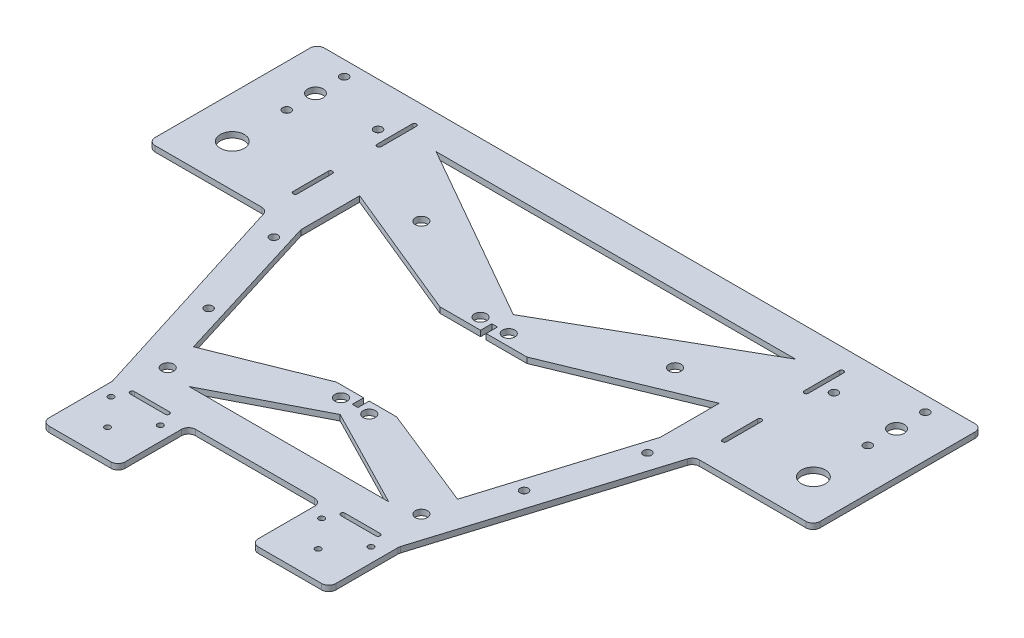
from build123d import *

# Parameters (mm, degrees)
SKETCH26_R          = 1
SKETCH26_R_2        = 2.15
SKETCH26_R_3        = 1.45
SKETCH26_R_4        = 4.25
SKETCH26_R_5        = 2.75
BOSS_EXTRUDE4_DEPTH = 2


with BuildPart() as part:
    # Sketch26 → Boss-Extrude4 (new body)
    with BuildSketch(Plane(origin=(0, 0, 0), x_dir=(1, 0, 0), z_dir=(0, 1, 0))):
        with BuildLine():
            Line((-20.877618357, -51.176455051), (21.352676296, -51.176455051))
            ThreePointArc((21.352676296, -51.176455051), (23.120443249, -51.908688098), (23.852676296, -53.676455051))
            Line((23.852676296, -53.676455051), (23.852676296, -73.676455051))
            ThreePointArc((23.852676296, -73.676455051), (24.584909343, -75.444222004), (26.352676296, -76.176455051))
            Line((26.352676296, -76.176455051), (48.872676296, -76.176455051))
            ThreePointArc((48.872676296, -76.176455051), (50.640443249, -75.444222004), (51.372676296, -73.676455051))
            Line((51.372676296, -73.676455051), (51.372676296, -51.552742091))
            ThreePointArc((51.372676296, -51.552742091), (51.400522432, -51.180646307), (51.483440514, -50.816839667))
            Line((51.483440514, -50.816839667), (75.469917209, 27.059447373))
            ThreePointArc((75.469917209, 27.059447373), (76.374187682, 28.334733163), (77.859152991, 28.823544949))
            Line((77.859152991, 28.823544949), (115.689249226, 28.823544949))
            ThreePointArc((115.689249226, 28.823544949), (117.457016179, 29.555777996), (118.189249226, 31.323544949))
            Line((118.189249226, 31.323544949), (118.189249226, 86.323544949))
            ThreePointArc((118.189249226, 86.323544949), (117.457016179, 88.091311902), (115.689249226, 88.823544949))
            Line((115.689249226, 88.823544949), (76.013272408, 88.823544949))
            Line((76.013272408, 88.823544949), (-75.538214468, 88.823544949))
            Line((-75.538214468, 88.823544949), (-76.032763958, 88.823544949))
            Line((-76.032763958, 88.823544949), (-115.214191287, 88.823544949))
            ThreePointArc((-115.214191287, 88.823544949), (-116.98195824, 88.091311902), (-117.714191287, 86.323544949))
            Line((-117.714191287, 86.323544949), (-117.714191287, 31.323544949))
            ThreePointArc((-117.714191287, 31.323544949), (-116.98195824, 29.555777996), (-115.214191287, 28.823544949))
            Line((-115.214191287, 28.823544949), (-77.373372177, 28.823544949))
            ThreePointArc((-77.373372177, 28.823544949), (-75.894006821, 28.338855879), (-74.98826724, 27.072727465))
            Line((-74.98826724, 27.072727465), (-50.52440331, -50.81067398))
            ThreePointArc((-50.52440331, -50.81067398), (-50.438398947, -51.180885745), (-50.409508246, -51.559856495))
            Line((-50.409508246, -51.559856495), (-50.409508246, -73.676455051))
            ThreePointArc((-50.409508246, -73.676455051), (-49.677275199, -75.444222004), (-47.909508246, -76.176455051))
            Line((-47.909508246, -76.176455051), (-25.877618357, -76.176455051))
            ThreePointArc((-25.877618357, -76.176455051), (-24.109851404, -75.444222004), (-23.377618357, -73.676455051))
            Line((-23.377618357, -73.676455051), (-23.377618357, -53.676455051))
            ThreePointArc((-23.377618357, -53.676455051), (-22.64538531, -51.908688098), (-20.877618357, -51.176455051))
        make_face()
        with Locations((-37.137618357, -66.176455051)):
            Circle(SKETCH26_R, mode=Mode.SUBTRACT)
        with Locations((-45.897618357, -56.176455051)):
            Circle(SKETCH26_R, mode=Mode.SUBTRACT)
        with Locations((-28.377618357, -56.176455051)):
            Circle(SKETCH26_R, mode=Mode.SUBTRACT)
        with BuildLine():
            Line((-43.378108588, -50.422722318), (-30.878108588, -50.422722318))
            ThreePointArc((-30.878108588, -50.422722318), (-30.128108588, -51.172722318), (-30.878108588, -51.922722318))
            Line((-30.878108588, -51.922722318), (-43.378108588, -51.922722318))
            ThreePointArc((-43.378108588, -51.922722318), (-44.128108588, -51.172722318), (-43.378108588, -50.422722318))
        make_face(mode=Mode.SUBTRACT)
        with Locations((-44.76247103, -37.176455051)):
            Circle(SKETCH26_R_2, mode=Mode.SUBTRACT)
        with Locations((-4.76247103, -15.676455051)):
            Circle(SKETCH26_R_2, mode=Mode.SUBTRACT)
        with Locations((-55.732763009, -11.697986619)):
            Circle(SKETCH26_R_3, mode=Mode.SUBTRACT)
        with Locations((28.852676296, -56.176455051)):
            Circle(SKETCH26_R, mode=Mode.SUBTRACT)
        with Locations((37.612676296, -66.176455051)):
            Circle(SKETCH26_R, mode=Mode.SUBTRACT)
        with Locations((46.372676296, -56.176455051)):
            Circle(SKETCH26_R, mode=Mode.SUBTRACT)
        with BuildLine():
            ThreePointArc((31.353166528, -51.922722318), (30.603166528, -51.172722318), (31.353166528, -50.422722318))
            Line((31.353166528, -50.422722318), (43.853166528, -50.422722318))
            ThreePointArc((43.853166528, -50.422722318), (44.603166528, -51.172722318), (43.853166528, -51.922722318))
            Line((43.853166528, -51.922722318), (31.353166528, -51.922722318))
        make_face(mode=Mode.SUBTRACT)
        with Locations((45.23752897, -37.176455051)):
            Circle(SKETCH26_R_2, mode=Mode.SUBTRACT)
        Polygon((35.658255702, -39.176455051), (-35.183197763, -39.176455051), (0.23752897, -20.965122509), align=None, mode=Mode.SUBTRACT)
        with Locations((5.23752897, -15.676455051)):
            Circle(SKETCH26_R_2, mode=Mode.SUBTRACT)
        with Locations((56.207820949, -11.697986619)):
            Circle(SKETCH26_R_3, mode=Mode.SUBTRACT)
        with Locations((-66.035396945, 21.75131433)):
            Circle(SKETCH26_R_3, mode=Mode.SUBTRACT)
        with Locations((-102.838214468, 43.823544949)):
            Circle(SKETCH26_R_4, mode=Mode.SUBTRACT)
        with BuildLine():
            ThreePointArc((-75.160005035, 39.191107079), (-75.910005035, 38.441107079), (-76.660005035, 39.191107079))
            Line((-76.660005035, 39.191107079), (-76.660005035, 51.691107079))
            ThreePointArc((-76.660005035, 51.691107079), (-75.910005035, 52.441107079), (-75.160005035, 51.691107079))
            Line((-75.160005035, 51.691107079), (-75.160005035, 39.191107079))
        make_face(mode=Mode.SUBTRACT)
        Polygon((-10.456903842, -11.676455051), (-46.597804641, -26.176455051), (-63.538214468, 28.823544949), (-63.538214468, 49.70968094), (-15.178445609, 29.823544949), (-0.76247103, 29.823544949), (-0.76247103, 33.823544949), (1.23752897, 33.823544949), (1.23752897, 29.823544949), (15.653503549, 29.823544949), (64.013272408, 49.70968094), (64.013272408, 28.823544949), (47.072862581, -26.176455051), (10.931961782, -11.676455051), (1.23752897, -11.676455051), (1.23752897, -15.676455051), (-0.76247103, -15.676455051), (-0.76247103, -11.676455051), align=None, mode=Mode.SUBTRACT)
        with Locations((-4.76247103, 33.823544949)):
            Circle(SKETCH26_R_2, mode=Mode.SUBTRACT)
        with Locations((-102.838214468, 63.123544949)):
            Circle(SKETCH26_R_3, mode=Mode.SUBTRACT)
        with Locations((-102.838214468, 73.323544949)):
            Circle(SKETCH26_R_5, mode=Mode.SUBTRACT)
        with Locations((-102.838214468, 83.523544949)):
            Circle(SKETCH26_R_3, mode=Mode.SUBTRACT)
        with Locations((-80.638214468, 73.323544949)):
            Circle(SKETCH26_R_3, mode=Mode.SUBTRACT)
        with BuildLine():
            ThreePointArc((-76.288214468, 81.095149015), (-75.538214468, 81.845149015), (-74.788214468, 81.095149015))
            Line((-74.788214468, 81.095149015), (-74.788214468, 68.595149015))
            ThreePointArc((-74.788214468, 68.595149015), (-75.538214468, 67.845149015), (-76.288214468, 68.595149015))
            Line((-76.288214468, 68.595149015), (-76.288214468, 81.095149015))
        make_face(mode=Mode.SUBTRACT)
        with Locations((-44.76247103, 52.823544949)):
            Circle(SKETCH26_R_2, mode=Mode.SUBTRACT)
        Polygon((0.23752897, 40.436613896), (-63.538214468, 76.823544949), (64.013272408, 76.823544949), align=None, mode=Mode.SUBTRACT)
        with Locations((5.23752897, 33.823544949)):
            Circle(SKETCH26_R_2, mode=Mode.SUBTRACT)
        with Locations((66.510454885, 21.75131433)):
            Circle(SKETCH26_R_3, mode=Mode.SUBTRACT)
        with BuildLine():
            Line((77.135062974, 51.691107079), (77.135062974, 39.191107079))
            ThreePointArc((77.135062974, 39.191107079), (76.385062974, 38.441107079), (75.635062974, 39.191107079))
            Line((75.635062974, 39.191107079), (75.635062974, 51.691107079))
            ThreePointArc((75.635062974, 51.691107079), (76.385062974, 52.441107079), (77.135062974, 51.691107079))
        make_face(mode=Mode.SUBTRACT)
        with Locations((103.313272408, 43.823544949)):
            Circle(SKETCH26_R_4, mode=Mode.SUBTRACT)
        with Locations((45.23752897, 52.823544949)):
            Circle(SKETCH26_R_2, mode=Mode.SUBTRACT)
        with Locations((103.313272408, 63.123544949)):
            Circle(SKETCH26_R_3, mode=Mode.SUBTRACT)
        with Locations((81.113272408, 73.323544949)):
            Circle(SKETCH26_R_3, mode=Mode.SUBTRACT)
        with BuildLine():
            Line((75.263272408, 68.595149015), (75.263272408, 81.095149015))
            ThreePointArc((75.263272408, 81.095149015), (76.013272408, 81.845149015), (76.763272408, 81.095149015))
            Line((76.763272408, 81.095149015), (76.763272408, 68.595149015))
            ThreePointArc((76.763272408, 68.595149015), (76.013272408, 67.845149015), (75.263272408, 68.595149015))
        make_face(mode=Mode.SUBTRACT)
        with Locations((103.313272408, 73.323544949)):
            Circle(SKETCH26_R_5, mode=Mode.SUBTRACT)
        with Locations((103.313272408, 83.523544949)):
            Circle(SKETCH26_R_3, mode=Mode.SUBTRACT)
    extrude(amount=BOSS_EXTRUDE4_DEPTH)


solid = part.part
